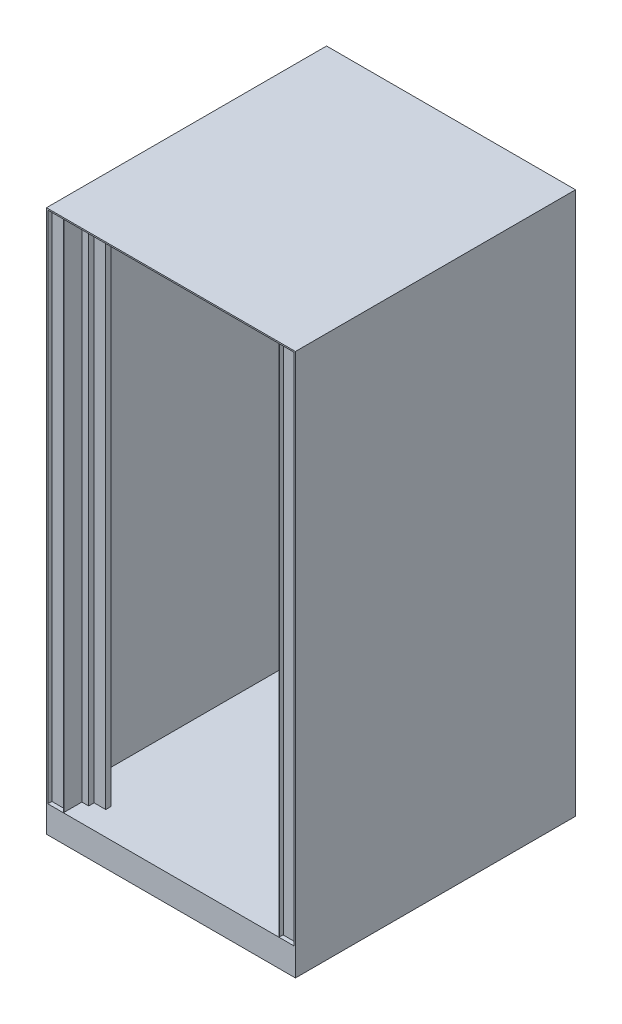
from build123d import *

# Parameters (mm, degrees)
CROQUIS1_W              = 920
CROQUIS1_H              = 2005
SALIENTE_EXTRUIR1_DEPTH = 1035
CROQUIS2_W              = 910
CROQUIS2_H              = 1900
CORTAR_EXTRUIR1_DEPTH   = 1025
SALIENTE_EXTRUIR2_DEPTH = 1900
SALIENTE_EXTRUIR3_DEPTH = 1900
SALIENTE_EXTRUIR4_DEPTH = 1900


with BuildPart() as part:
    # Croquis1 → Saliente-Extruir1 (new body)
    with BuildSketch(Plane.XY):
        Rectangle(CROQUIS1_W, CROQUIS1_H)
    extrude(amount=SALIENTE_EXTRUIR1_DEPTH)

    # Croquis2 → Cortar-Extruir1 (cut)
    with BuildSketch(Plane.XY.offset(1035)):
        with Locations((0, 47.5)):
            Rectangle(CROQUIS2_W, CROQUIS2_H)
    extrude(amount=-CORTAR_EXTRUIR1_DEPTH, mode=Mode.SUBTRACT)

    # Croquis3 → Saliente-Extruir2 (add)
    with BuildSketch(Plane(origin=(0, -902.5, 0), x_dir=(1, 0, 0), z_dir=(0, 1, 0))):
        Polygon((-406, -59), (-425, -59), (-425, -65), (-455, -65), (-455, -10), (-400, -10), (-400, -40), (-406, -40), align=None)
        Polygon((400, -10), (400, -40), (406, -40), (406, -59), (425, -59), (425, -65), (455, -65), (455, -10), align=None)
    extrude(amount=SALIENTE_EXTRUIR2_DEPTH)

    # Croquis4 → Saliente-Extruir3 (add)
    with BuildSketch(Plane(origin=(0, -902.5, 0), x_dir=(1, 0, 0), z_dir=(0, 1, 0))):
        Polygon((-455, -965), (-425, -965), (-425, -971), (-406, -971), (-406, -989.913190258), (-400, -989.913190258), (-400, -1019.913190258), (-455, -1019.913190258), align=None)
        Polygon((406, -971), (406, -989.913190258), (400, -989.913190258), (400, -1019.913190258), (455, -1019.913190258), (455, -965), (425, -965), (425, -971), align=None)
    extrude(amount=SALIENTE_EXTRUIR3_DEPTH)

    # Croquis5 → Saliente-Extruir4 (add)
    with BuildSketch(Plane(origin=(0, -902.5, 0), x_dir=(1, 0, 0), z_dir=(0, 1, 0))):
        Polygon((-399, -1033), (-399, -965), (-374, -965), (-374, -945), (-331, -945), (-331, -927), (-329.5, -927), (-329.5, -946.5), (-372.5, -946.5), (-372.5, -966.5), (-397.5, -966.5), (-397.5, -981.854825443), (-397.5, -1033), align=None)
        Polygon((397.5, -1033), (399, -1033), (399, -965), (374, -965), (374, -945), (331, -945), (331, -927), (329.5, -927), (329.5, -946.5), (372.5, -946.5), (372.5, -966.5), (397.5, -966.5), (397.5, -981.854825443), align=None)
    extrude(amount=SALIENTE_EXTRUIR4_DEPTH)


solid = part.part
